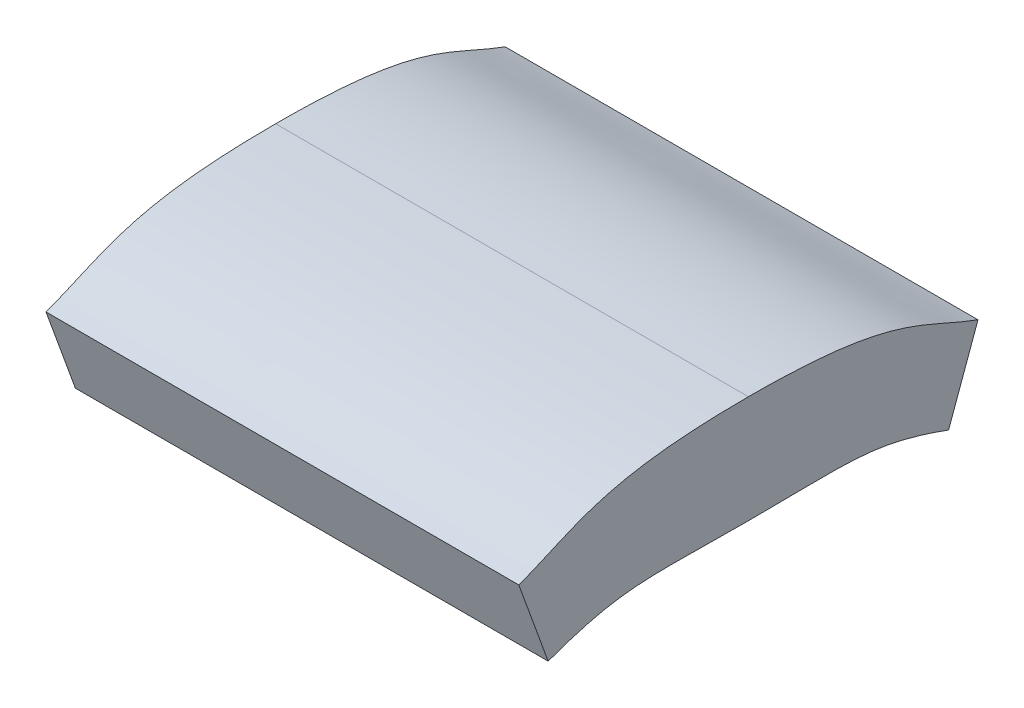
from build123d import *

# Parameters (mm, degrees)
BOSS_EXTRUDE1_DEPTH = 22


with BuildPart() as part:
    # Sketch1 → Boss-Extrude1 (new body)
    with BuildSketch(Plane(origin=(0, 0, 0), x_dir=(0, 0, -1), z_dir=(1, 0, 0))):
        with BuildLine():
            Line((9.315959713, -0.977926899), (10.684040287, 2.780843585))
            add(Edge.make_bspline(
                [(10.684040287, 2.780843585), (8.015434701, 3.752136585), (6.887064051, 5.022073101), (0, 5.022073101)],
                knots=[0, 0, 0, 0, 1, 1, 1, 1], degree=3))
            add(Edge.make_bspline(
                [(-10.684040287, 2.780843585), (-8.015434701, 3.752136585), (-6.887064051, 5.022073101), (0, 5.022073101)],
                knots=[0, 0, 0, 0, 1, 1, 1, 1], degree=3))
            Line((-10.684040287, 2.780843585), (-9.315959713, -0.977926899))
            add(Edge.make_bspline(
                [(-9.315959713, -0.977926899), (-5.7702052, 0.312622202), (-4.685194012, 0.022073101), (0, 0.022073101)],
                knots=[0, 0, 0, 0, 1, 1, 1, 1], degree=3))
            add(Edge.make_bspline(
                [(9.315959713, -0.977926899), (5.7702052, 0.312622202), (4.685194012, 0.022073101), (0, 0.022073101)],
                knots=[0, 0, 0, 0, 1, 1, 1, 1], degree=3))
        make_face()
    extrude(amount=BOSS_EXTRUDE1_DEPTH)


solid = part.part
